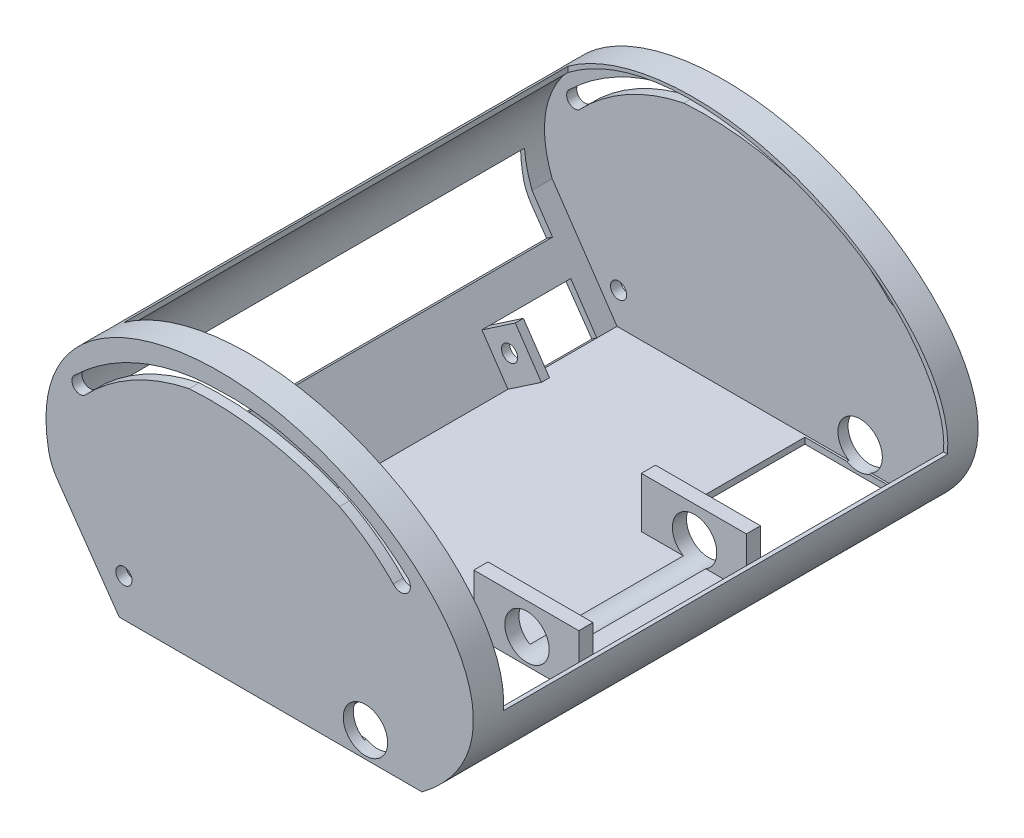
from build123d import *

# Parameters (mm, degrees)
BOSS_EXTRUDE1_DEPTH      = 250
CUT_EXTRUDE1_START       = -5
CUT_EXTRUDE1_DEPTH       = 240
CUT_EXTRUDE2_START       = 40
SKETCH3_W                = 188.244995532
SKETCH3_H                = 220
CUT_EXTRUDE2_DEPTH       = 236
FILLET1_R                = 25
SKETCH16_W               = 40
SKETCH16_H               = 23
CUT_EXTRUDE11_DEPTH      = 170
SKETCH17_W               = 4
SKETCH17_H               = 24.99344169
SKETCH17_H_2             = 23
BOSS_EXTRUDE5_DEPTH      = 20
SKETCH18_R               = 4
CUT_EXTRUDE12_DEPTH      = 56.0000001
CUT_EXTRUDE12_DEPTH_BACK = 196.0000001
SKETCH26_W               = 52
SKETCH26_H               = 74
CUT_EXTRUDE13_DEPTH      = 10
SKETCH27_W               = 52
SKETCH27_H               = 7
BOSS_EXTRUDE6_DEPTH      = 25
SKETCH29_R               = 11
CUT_EXTRUDE14_DEPTH      = 164.0000001
CUT_EXTRUDE14_DEPTH_BACK = 88.0000001
SKETCH31_W               = 220
SKETCH31_H               = 33.637756758
CUT_EXTRUDE15_DEPTH      = 216.289478638
CUT_EXTRUDE15_DEPTH_BACK = 33.977288489
CUT_EXTRUDE17_DEPTH      = 1.0000001
CUT_EXTRUDE17_DEPTH_BACK = 251.0000001


with BuildPart() as part:
    # Sketch1 → Boss-Extrude1 (new body)
    with BuildSketch(Plane.XY):
        with BuildLine():
            Line((-74.466852712, 0), (75.533147288, 0))
            add(Edge.make_bspline(
                [(75.533147288, 0), (138.063372934, 47.200510513), (16.470001542, 172.007803308), (-124.949591118, 111.301552399), (-108.081203548, 48.03596108)],
                knots=[0, 0, 0, 0, 0.526874503, 1, 1, 1, 1], degree=3))
            Line((-108.081203548, 48.03596108), (-74.466852712, 0))
        make_face()
    extrude(amount=BOSS_EXTRUDE1_DEPTH)

    # Sketch2 → Cut-Extrude1 (cut)
    with BuildSketch(Plane.XY.offset(250).offset(CUT_EXTRUDE1_START)):
        with BuildLine():
            Line((-105.002588912, 50.278247003), (-72.903738951, 3))
            Line((-72.903738951, 3), (73.163375947, 3))
            Line((73.163375947, 3), (75.554047329, 3))
            Line((75.554047329, 3), (85.055106359, 11.591701144))
            ThreePointArc((85.055106359, 11.591701144), (89.402345548, 17.022720611), (92.788433069, 23.09963367))
            add(Edge.make_bspline(
                [(92.788433069, 23.09963367), (96.812719468, 29.154161293), (103.314814409, 50.201439356), (80.501543446, 89.980370093), (42.540150732, 114.005749807), (-11.832065214, 131.764317978), (-81.096743835, 126.81989126), (-117.24410327, 82.158250279), (-105.002588912, 50.278247003)],
                knots=[0.063093748, 0.063093748, 0.063093748, 0.063093748, 0.12675304, 0.268313114, 0.414746674, 0.542882576, 0.761532881, 1, 1, 1, 1], degree=3))
        make_face()
    extrude(amount=-CUT_EXTRUDE1_DEPTH, mode=Mode.SUBTRACT)

    # Sketch3 → Cut-Extrude2 (cut)
    with BuildSketch(Plane(origin=(0, 0, 0), x_dir=(1, 0, 0), z_dir=(0, 1, 0)).offset(CUT_EXTRUDE2_START)):
        with Locations((6.82953452, -125)):
            Rectangle(SKETCH3_W, SKETCH3_H)
    extrude(amount=CUT_EXTRUDE2_DEPTH, mode=Mode.SUBTRACT)

    # Fillet1
    fillet1_edges = [part.edges().sort_by_distance(p)[0] for p in [
        (-108.081203548, 48.03596108, 125),
    ]]
    fillet(fillet1_edges, radius=FILLET1_R)

    # Sketch16 → Cut-Extrude11 (cut)
    with BuildSketch(Plane(origin=(-48.507348666, -32.933329925, 0), x_dir=(0, 0, -1), z_dir=(0.827336045, 0.561707281, 0))):
        with Locations((-212.328725108, 56.926010788)):
            Rectangle(SKETCH16_W, SKETCH16_H)
        with Locations((-35, 54.932569098)):
            Rectangle(SKETCH16_W, SKETCH16_H)
    extrude(amount=-CUT_EXTRUDE11_DEPTH, mode=Mode.SUBTRACT)

    # Sketch17 → Boss-Extrude5 (add)
    with BuildSketch(Plane(origin=(-48.507348666, -32.933329925, 0), x_dir=(0, 0, -1), z_dir=(0.827336045, 0.561707281, 0))):
        with Locations((-190.328725108, 55.929289943)):
            Rectangle(SKETCH17_W, SKETCH17_H)
        with Locations((-57, 54.932569098)):
            Rectangle(SKETCH17_W, SKETCH17_H_2)
    extrude(amount=BOSS_EXTRUDE5_DEPTH)

    # Sketch18 → Cut-Extrude12 (cut, two sides)
    with BuildSketch(Plane(origin=(0, 0, 55), x_dir=(-1, 0, 0), z_dir=(0, 0, -1))) as cut_extrude12_sk:
        with Locations((72.12467311, 18.843671615)):
            Circle(SKETCH18_R)
    extrude(amount=CUT_EXTRUDE12_DEPTH, mode=Mode.SUBTRACT)
    extrude(cut_extrude12_sk.sketch, amount=-CUT_EXTRUDE12_DEPTH_BACK, mode=Mode.SUBTRACT)

    # Sketch26 → Cut-Extrude13 (cut)
    with BuildSketch(Plane(origin=(0, 3, 0), x_dir=(1, 0, 0), z_dir=(0, 1, 0))):
        with Locations((47.163460131, -207)):
            Rectangle(SKETCH26_W, SKETCH26_H)
    cut_extrude13 = extrude(amount=-CUT_EXTRUDE13_DEPTH, mode=Mode.SUBTRACT)

    # Sketch27 → Boss-Extrude6 (add)
    with BuildSketch(Plane(origin=(0, 3, 0), x_dir=(1, 0, 0), z_dir=(0, 1, 0))):
        with Locations((47.163460131, -166.5)):
            Rectangle(SKETCH27_W, SKETCH27_H)
    boss_extrude6 = extrude(amount=BOSS_EXTRUDE6_DEPTH)

    # Mirror1: Cut-Extrude13, Boss-Extrude6 across plane
    add(cut_extrude13.mirror(Plane.XY.offset(125)), mode=Mode.SUBTRACT)
    add(boss_extrude6.mirror(Plane.XY.offset(125)))

    # Sketch29 → Cut-Extrude14 (cut, two sides)
    with BuildSketch(Plane.XY.offset(87)) as cut_extrude14_sk:
        with Locations((47.502101682, 12.5)):
            Circle(SKETCH29_R)
    extrude(amount=CUT_EXTRUDE14_DEPTH, mode=Mode.SUBTRACT)
    extrude(cut_extrude14_sk.sketch, amount=-CUT_EXTRUDE14_DEPTH_BACK, mode=Mode.SUBTRACT)

    # Sketch31 → Cut-Extrude15 (cut, two sides)
    with BuildSketch(Plane(origin=(-48.507348666, -32.933329925, 0), x_dir=(0, 0, -1), z_dir=(0.827336045, 0.561707281, 0))) as cut_extrude15_sk:
        with Locations((-125, 99.296236359)):
            Rectangle(SKETCH31_W, SKETCH31_H)
    extrude(amount=CUT_EXTRUDE15_DEPTH, mode=Mode.SUBTRACT)
    extrude(cut_extrude15_sk.sketch, amount=-CUT_EXTRUDE15_DEPTH_BACK, mode=Mode.SUBTRACT)

    # Sketch33 → Cut-Extrude17 (cut, two sides)
    with BuildSketch(Plane.XY.offset(250)) as cut_extrude17_sk:
        with BuildLine():
            ThreePointArc((-96.139108118, 93.087727905), (-97.176714819, 87.547181157), (-91.636168071, 86.509574455))
            ThreePointArc((-91.636168071, 86.509574455), (-67.942373177, 104.932123716), (-39.780049997, 115.308529202))
            ThreePointArc((-39.780049997, 115.308529202), (-1.727579676, 113.255761081), (34.673746596, 101.979777748))
            ThreePointArc((34.673746596, 101.979777748), (48.746993578, 93.12467921), (61.24866353, 82.162138486))
            ThreePointArc((61.24866353, 82.162138486), (67.933695568, 81.366522268), (68.729311786, 88.051554307))
            ThreePointArc((68.729311786, 88.051554307), (43.326237947, 106.145331635), (14.145463416, 117.153661945))
            ThreePointArc((14.145463416, 117.153661945), (-5.006170904, 121.228745495), (-24.572430668, 121.972305781))
            ThreePointArc((-24.572430668, 121.972305781), (-63.160343802, 114.478848604), (-96.139108118, 93.087727905))
        make_face()
    extrude(amount=CUT_EXTRUDE17_DEPTH, mode=Mode.SUBTRACT)
    extrude(cut_extrude17_sk.sketch, amount=-CUT_EXTRUDE17_DEPTH_BACK, mode=Mode.SUBTRACT)


solid = part.part
